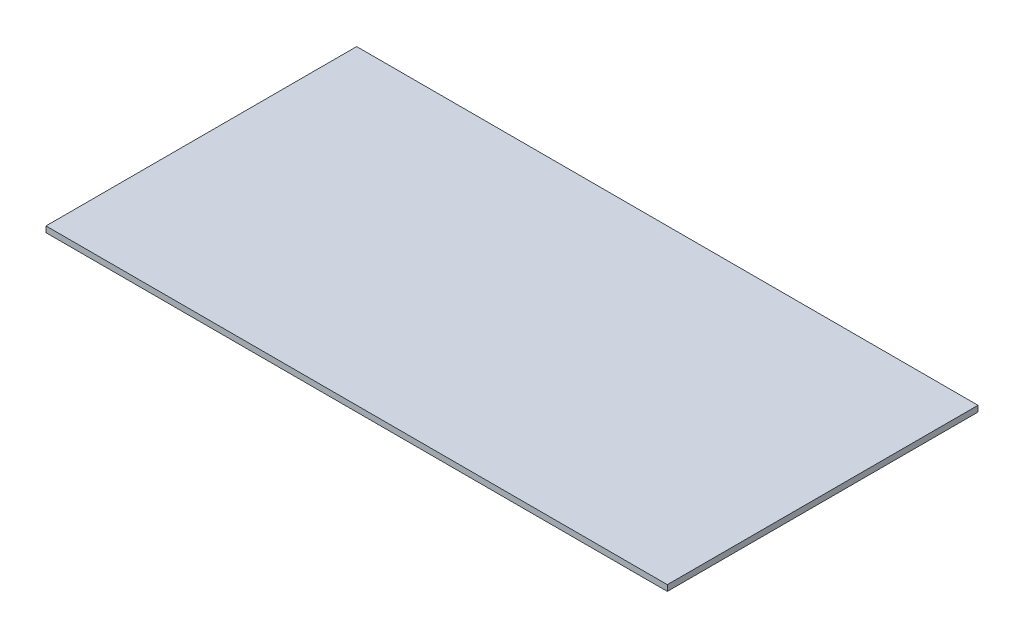
from build123d import *

# Parameters (mm, degrees)
SKETCH1_W           = 501.65
SKETCH1_H           = 250.825
BOSS_EXTRUDE1_DEPTH = 4.7625


with BuildPart() as part:
    # Sketch1 → Boss-Extrude1 (new body)
    with BuildSketch(Plane(origin=(0, 0, 0), x_dir=(1, 0, 0), z_dir=(0, 1, 0))):
        with Locations((250.825, -125.4125)):
            Rectangle(SKETCH1_W, SKETCH1_H)
    extrude(amount=BOSS_EXTRUDE1_DEPTH)


solid = part.part
